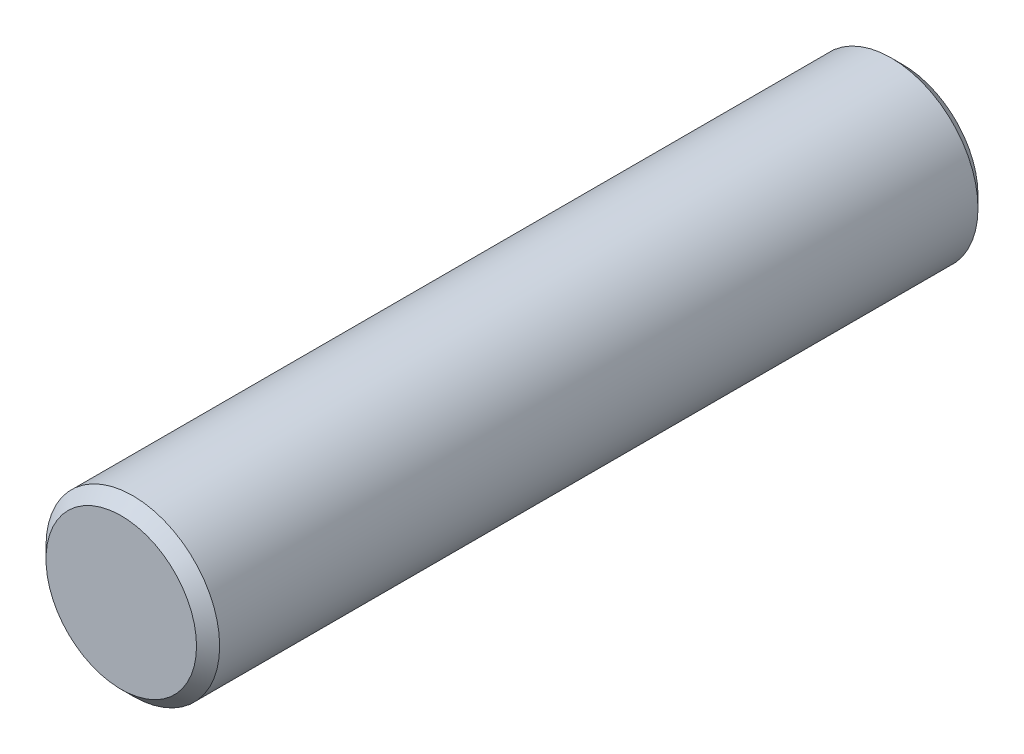
from build123d import *

# Parameters (mm, degrees)
SKETCH1_R           = 1.5
BOSS_EXTRUDE1_DEPTH = 13.5
CHAMFER1_SIZE       = 0.2


with BuildPart() as part:
    # Sketch1 → Boss-Extrude1 (new body)
    with BuildSketch(Plane.XY):
        Circle(SKETCH1_R)
    extrude(amount=BOSS_EXTRUDE1_DEPTH)

    # Chamfer1
    chamfer1_edges = [part.edges().sort_by_distance(p)[0] for p in [
        (-1.5, 0, 0),
        (-1.5, 0, 13.5),
    ]]
    chamfer(chamfer1_edges, length=CHAMFER1_SIZE)


solid = part.part
